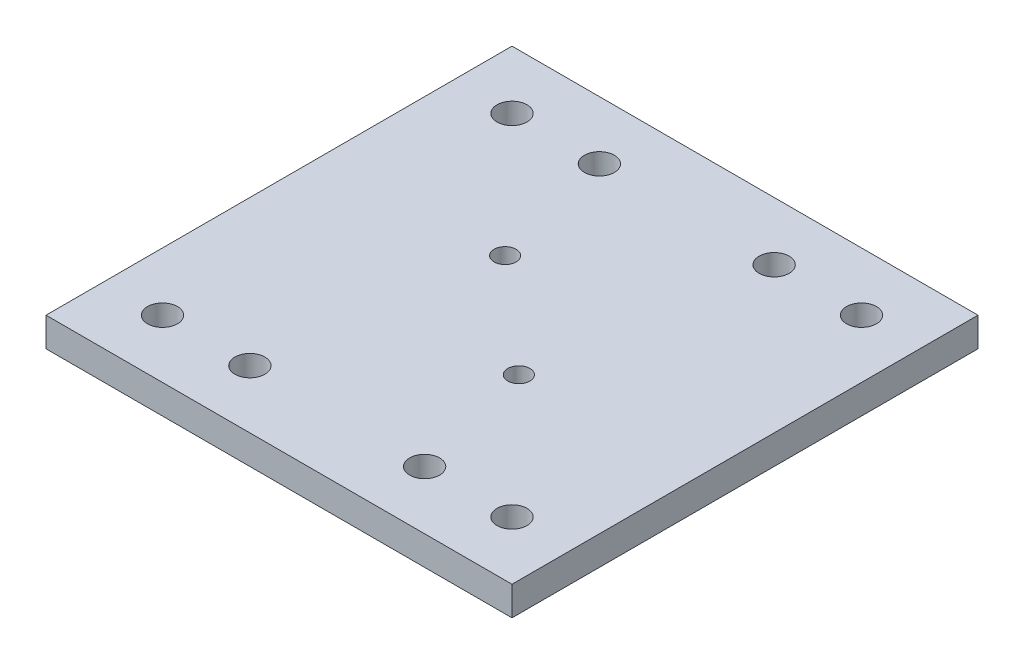
from build123d import *

# Parameters (mm, degrees)
SKETCH1_W             = 50.8
SKETCH1_H             = 50.8
BOSS_EXTRUDE1_DEPTH   = 3.175
M2_CLEARANCE_HOLE1_D  = 2.4
F_4_CLEARANCE_HOLE1_D = 3.2639
F_4_CLEARANCE_HOLE2_D = 3.2639


with BuildPart() as part:
    # Sketch1 → Boss-Extrude1 (new body)
    with BuildSketch(Plane(origin=(0, 0, 0), x_dir=(1, 0, 0), z_dir=(0, 1, 0))):
        Rectangle(SKETCH1_W, SKETCH1_H)
    extrude(amount=BOSS_EXTRUDE1_DEPTH)

    # M2 Clearance Hole1 (through all)
    with Locations(Plane(origin=(0, 3.175, 0), x_dir=(1, 0, 0), z_dir=(0, 1, 0))):
        with Locations((6, -5.25), (-6, 5.25)):
            Hole(M2_CLEARANCE_HOLE1_D / 2)

    # #4 Clearance Hole1 (through all)
    with Locations(Plane(origin=(0, 3.175, 0), x_dir=(1, 0, 0), z_dir=(0, 1, 0))):
        with Locations((-19.05, -19.05), (19.05, 19.05), (19.05, -19.05), (-19.05, 19.05)):
            Hole(F_4_CLEARANCE_HOLE1_D / 2)

    # #4 Clearance Hole2 (through all)
    with Locations(Plane(origin=(-33.504228334, 3.175, -53.736749861), x_dir=(1, 0, 0), z_dir=(0, 1, 0))):
        with Locations((23.979228334, -34.686749861), (43.029228334, -34.686749861), (43.029228334, -72.786749861), (23.979228334, -72.786749861)):
            Hole(F_4_CLEARANCE_HOLE2_D / 2)


solid = part.part
